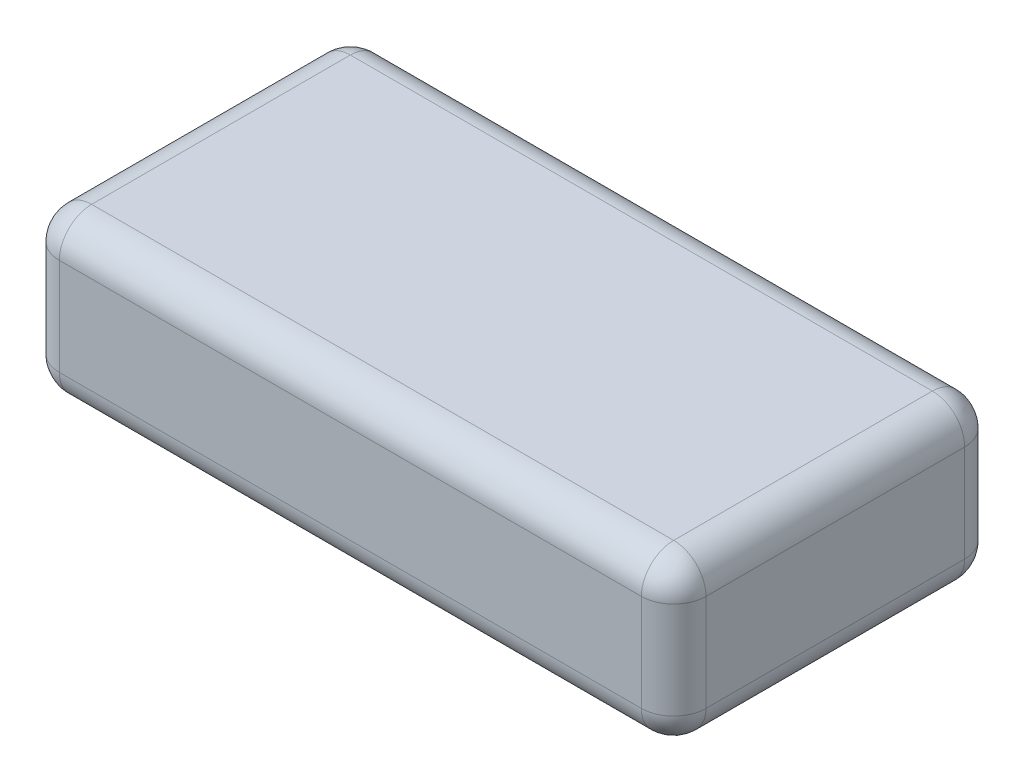
from build123d import *

# Parameters (mm, degrees)
SKETCH_1_W      = 60
SKETCH_1_H      = 30
EXTRUDE_1_DEPTH = 15
FILLET_1_R      = 3


with BuildPart() as part:
    # 草图1 → 凸台-拉伸1 (new body)
    with BuildSketch(Plane(origin=(0, 0, 0), x_dir=(1, 0, 0), z_dir=(0, 1, 0))):
        with Locations((30, 15)):
            Rectangle(SKETCH_1_W, SKETCH_1_H)
    extrude(amount=EXTRUDE_1_DEPTH)

    # 圆角1
    fillet_1_edges = [part.edges().sort_by_distance(p)[0] for p in [
        (60, 15, -15),
        (30, 15, -30),
        (0, 15, -15),
        (30, 0, -30),
        (60, 0, -15),
        (30, 0, 0),
        (0, 0, -15),
        (30, 15, 0),
        (0, 7.5, -30),
        (60, 7.5, -30),
        (60, 7.5, 0),
        (0, 7.5, 0),
    ]]
    fillet(fillet_1_edges, radius=FILLET_1_R)


solid = part.part
